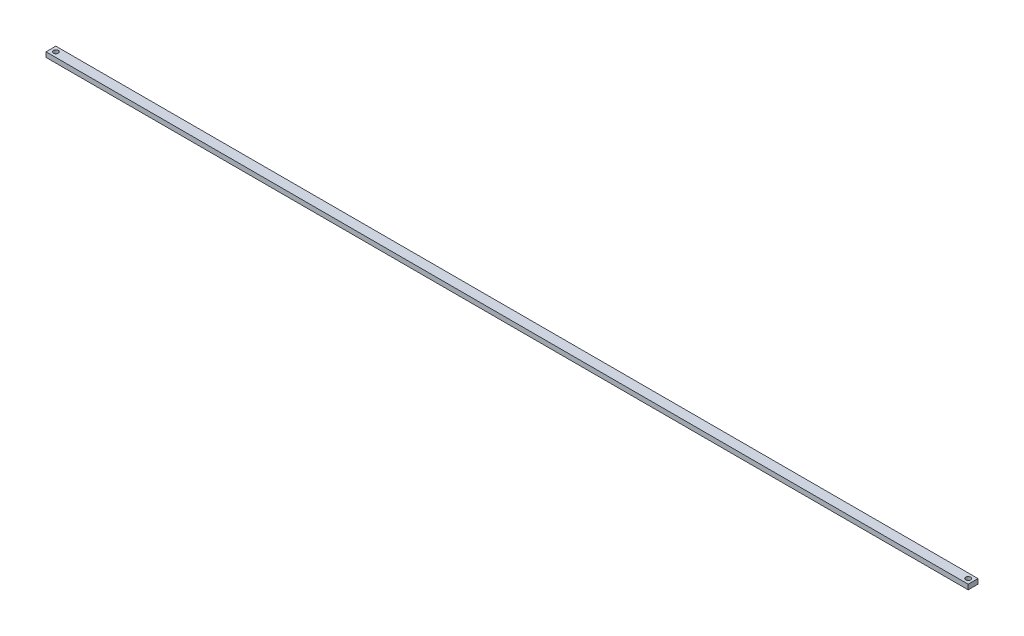
from build123d import *

# Parameters (mm, degrees)
SKETCH1_W           = 596.9
SKETCH1_H           = 6.35
SKETCH1_R           = 1.5875
BOSS_EXTRUDE1_DEPTH = 3.175


with BuildPart() as part:
    # Sketch1 → Boss-Extrude1 (new body)
    with BuildSketch(Plane(origin=(0, 0, 0), x_dir=(1, 0, 0), z_dir=(0, 1, 0))):
        with Locations((298.45, -3.175)):
            Rectangle(SKETCH1_W, SKETCH1_H)
        with Locations((3.175, -3.175)):
            Circle(SKETCH1_R, mode=Mode.SUBTRACT)
        with Locations((593.725, -3.175)):
            Circle(SKETCH1_R, mode=Mode.SUBTRACT)
    extrude(amount=BOSS_EXTRUDE1_DEPTH)


solid = part.part
